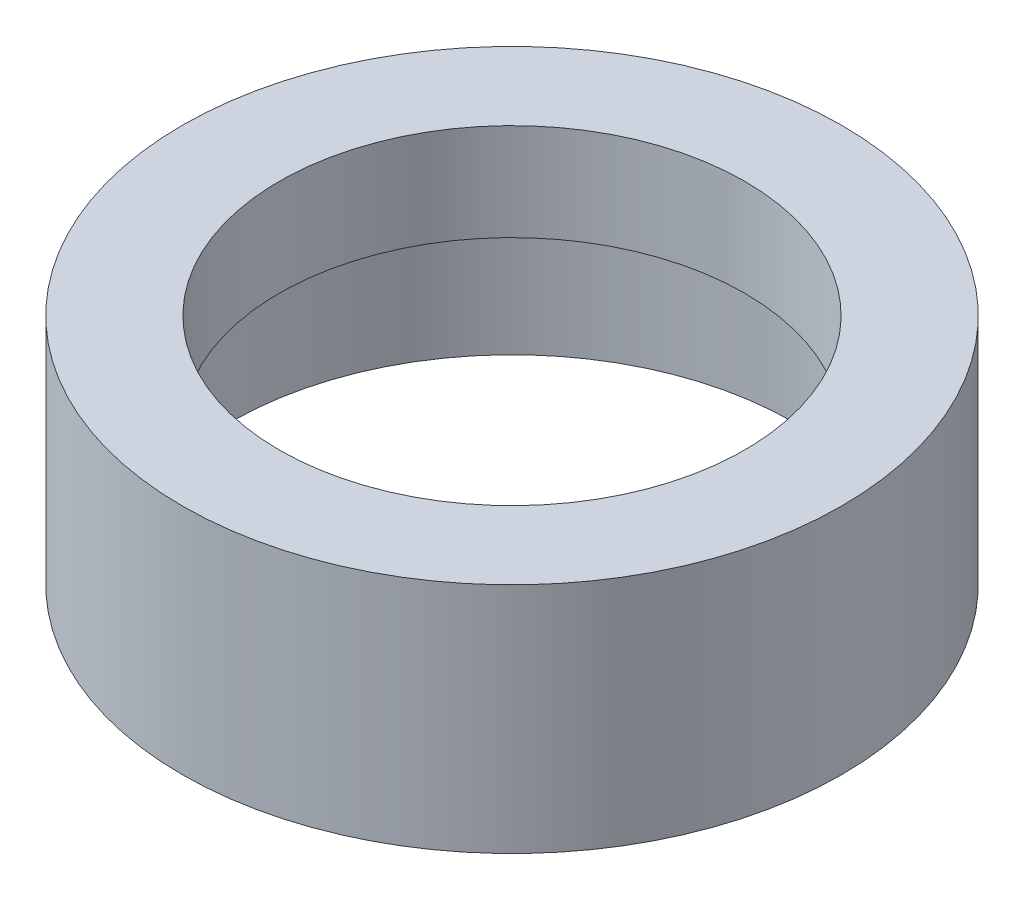
from build123d import *

# Parameters (mm, degrees)
ESQUISSE1_R             = 17
ESQUISSE1_R_2           = 12
BOSS_EXTRU_1_DEPTH      = 12
ESQUISSE2_R             = 14.5
ENL_V_MAT_EXTRU_1_DEPTH = 7


with BuildPart() as part:
    # Esquisse1 → Boss.-Extru.1 (new body)
    with BuildSketch(Plane(origin=(0, 0, 0), x_dir=(1, 0, 0), z_dir=(0, 1, 0))):
        with Locations(Location((0, 0, 0), (0, 0, 270))):  # turned: the seam where the file's is
            Circle(ESQUISSE1_R)
        with Locations(Location((0, 0, 0), (0, 0, 270))):  # turned: the seam where the file's is
            Circle(ESQUISSE1_R_2, mode=Mode.SUBTRACT)
    extrude(amount=BOSS_EXTRU_1_DEPTH)

    # Esquisse2 → Enlèv. mat.-Extru.1 (cut)
    with BuildSketch(Plane.XZ):
        with Locations(Location((0, 0, 0), (0, 0, 270))):  # turned: the seam where the file's is
            Circle(ESQUISSE2_R)
    extrude(amount=-ENL_V_MAT_EXTRU_1_DEPTH, mode=Mode.SUBTRACT)


solid = part.part
